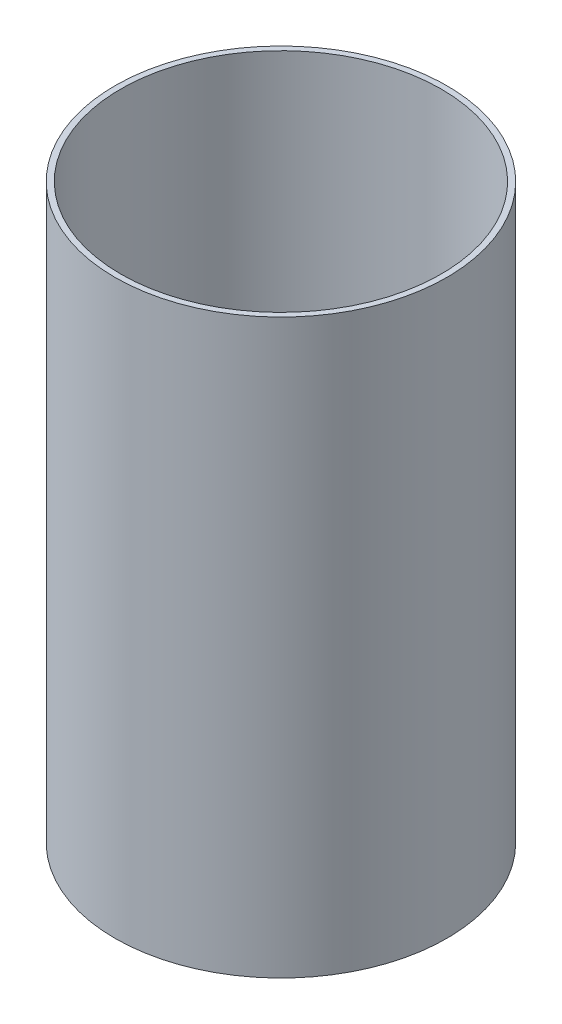
from build123d import *

# Parameters (mm, degrees)
SKETCH_1_R          = 14.5
EXTRUDE_1_DEPTH     = 50
SKETCH_2_R          = 14
CUT_EXTRUDE_1_DEPTH = 49


with BuildPart() as part:
    # Эскиз1 → Бобышка-Вытянуть1 (new body)
    with BuildSketch(Plane(origin=(0, 0, 0), x_dir=(1, 0, 0), z_dir=(0, 1, 0))):
        Circle(SKETCH_1_R)
    extrude(amount=EXTRUDE_1_DEPTH)

    # Эскиз2 → Вырез-Вытянуть1 (cut)
    with BuildSketch(Plane(origin=(0, 50, 0), x_dir=(1, 0, 0), z_dir=(0, 1, 0))):
        Circle(SKETCH_2_R)
    extrude(amount=-CUT_EXTRUDE_1_DEPTH, mode=Mode.SUBTRACT)


solid = part.part
